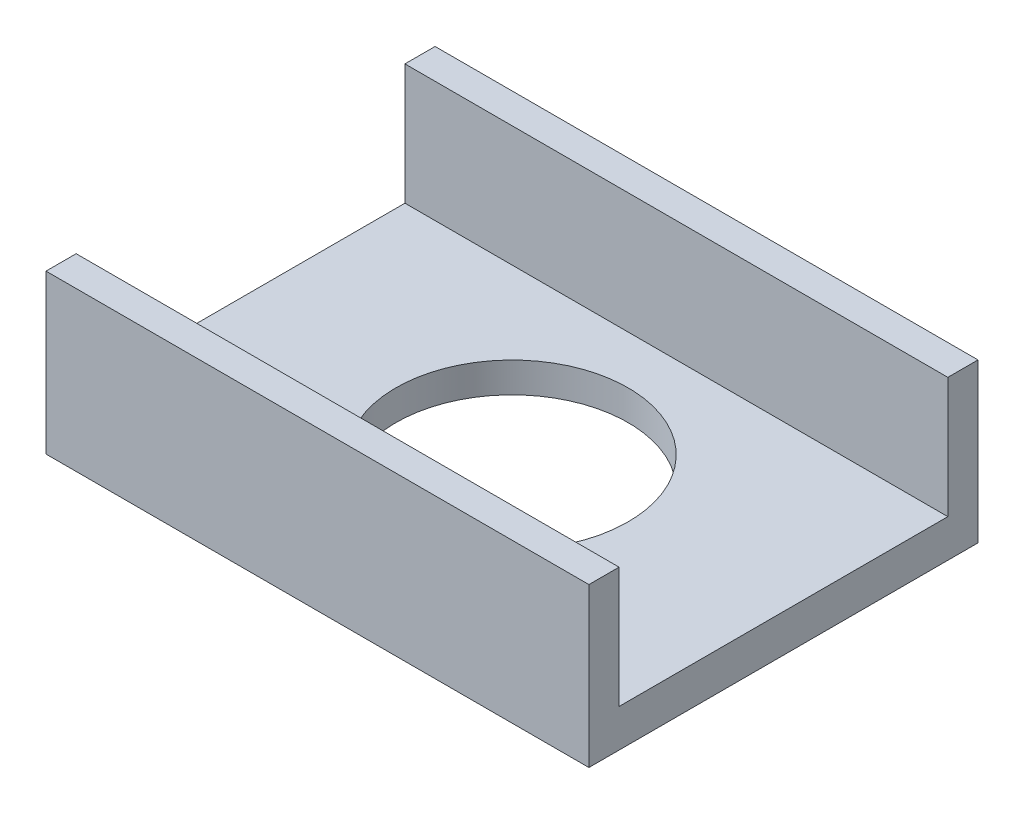
from build123d import *

# Parameters (mm, degrees)
SKETCH1_W               = 80
SKETCH1_H               = 54.5
BOSS_EXTRUDE1_DEPTH     = 1.27
SHELL4_T                = 5
SKETCH7_W               = 90
SKETCH7_H               = 5
BOSS_EXTRUDE4_DEPTH     = 20
CUT_EXTRUDE3_DEPTH      = 61.745884634
CUT_EXTRUDE3_DEPTH_BACK = 61.745884634
SKETCH1_5_R             = 19.25


with BuildPart() as part:
    # Sketch1 → Boss-Extrude1 (new body)
    with BuildSketch(Plane(origin=(0, 0, 0), x_dir=(1, 0, 0), z_dir=(0, 1, 0))):
        Rectangle(SKETCH1_W, SKETCH1_H)
    extrude(amount=-BOSS_EXTRUDE1_DEPTH)

    # Shell4
    shell4_openings = [part.faces().sort_by_distance(p)[0] for p in [
        (0, -1.27, 0),
    ]]
    offset(amount=SHELL4_T, openings=shell4_openings, kind=Kind.INTERSECTION)

    # Sketch7 → Boss-Extrude4 (add)
    with BuildSketch(Plane(origin=(0, 5, 0), x_dir=(1, 0, 0), z_dir=(0, 1, 0))):
        with Locations((0, 29.75)):
            Rectangle(SKETCH7_W, SKETCH7_H)
        with Locations((0, -29.75)):
            Rectangle(SKETCH7_W, SKETCH7_H)
    extrude(amount=BOSS_EXTRUDE4_DEPTH)

    # Sketch1_5 → Cut-Extrude3 (cut, two sides: drawn at the far end of the back side and taken through both)
    with BuildSketch(Plane(origin=(0, 0, 0), x_dir=(1, 0, 0), z_dir=(0, 1, 0)).offset(-CUT_EXTRUDE3_DEPTH_BACK)):
        Circle(SKETCH1_5_R)
    extrude(amount=CUT_EXTRUDE3_DEPTH + CUT_EXTRUDE3_DEPTH_BACK, mode=Mode.SUBTRACT)


solid = part.part
